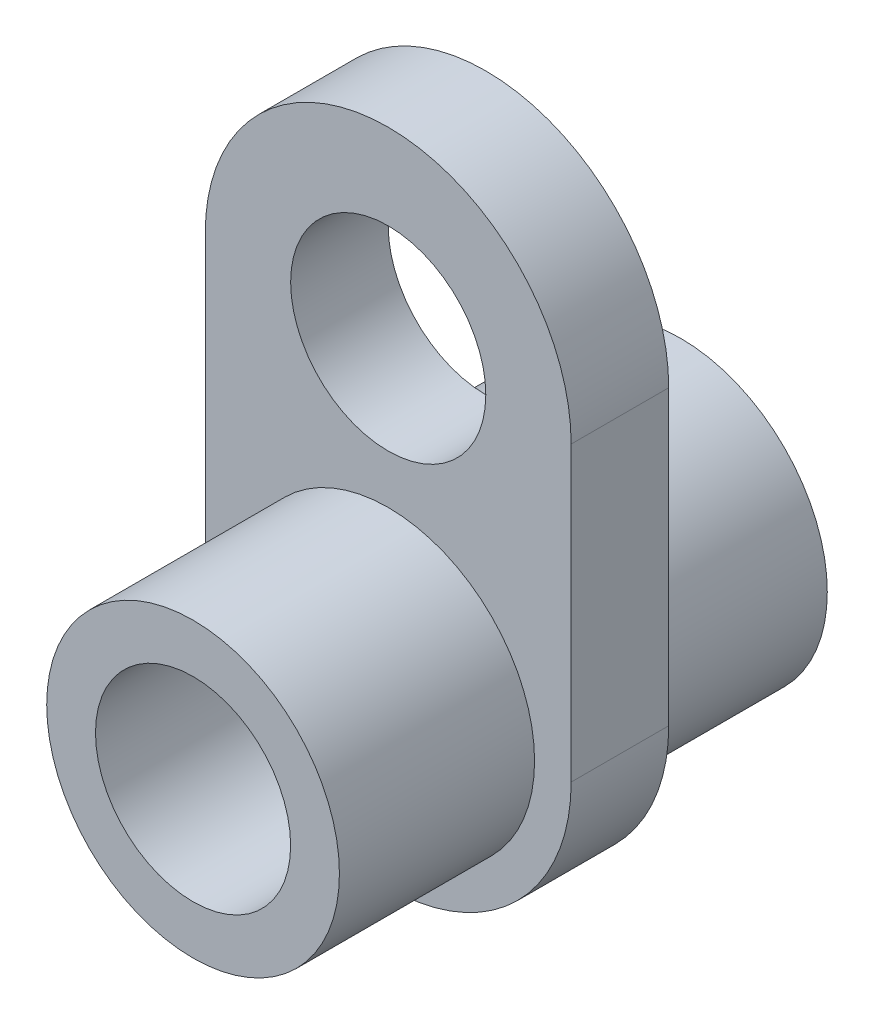
from build123d import *

# Parameters (mm, degrees)
SALIENTE_EXTRUIR1_DEPTH      = 2
SALIENTE_EXTRUIR1_DEPTH_BACK = 2
CROQUIS2_R                   = 4
SALIENTE_EXTRUIR2_DEPTH      = 10
SALIENTE_EXTRUIR2_DEPTH_BACK = 10
CROQUIS2_3_R                 = 6
CROQUIS2_3_R_2               = 4


with BuildPart() as part:
    # Croquis2 → Saliente-Extruir1 (new, two sides: drawn at the far end of the back side and taken through both)
    with BuildSketch(Plane.XY.offset(-SALIENTE_EXTRUIR1_DEPTH_BACK)):
        with BuildLine():
            Line((7.5, -6), (7.5, 6))
            ThreePointArc((7.5, 6), (0, 13.5), (-7.5, 6))
            Line((-7.5, 6), (-7.5, -6))
            ThreePointArc((-7.5, -6), (0, -13.5), (7.5, -6))
        make_face()
        with Locations((0, 6)):
            Circle(CROQUIS2_R, mode=Mode.SUBTRACT)
        with Locations((0, -6)):
            Circle(CROQUIS2_R, mode=Mode.SUBTRACT)
    extrude(amount=SALIENTE_EXTRUIR1_DEPTH + SALIENTE_EXTRUIR1_DEPTH_BACK)

    # Croquis2_3 → Saliente-Extruir2 (add, two sides: drawn at the far end of the back side and taken through both)
    with BuildSketch(Plane.XY.offset(-SALIENTE_EXTRUIR2_DEPTH_BACK)):
        with Locations((0, -6)):
            Circle(CROQUIS2_3_R)
        with Locations((0, -6)):
            Circle(CROQUIS2_3_R_2, mode=Mode.SUBTRACT)
    extrude(amount=SALIENTE_EXTRUIR2_DEPTH + SALIENTE_EXTRUIR2_DEPTH_BACK)


solid = part.part
